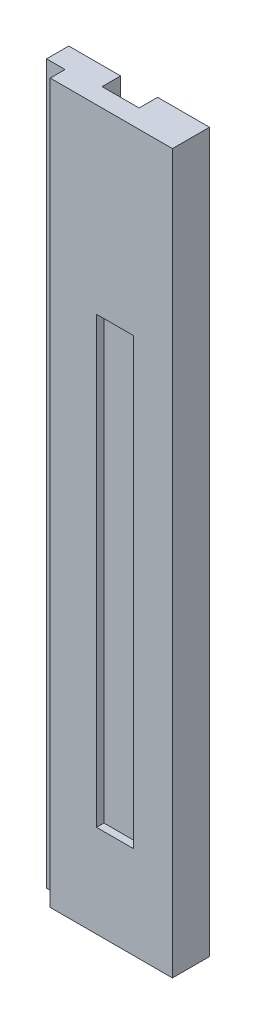
from build123d import *

# Parameters (mm, degrees)
SKETCH1_W            = 14
SKETCH1_H            = 100
BOSS_EXTRUDE1_DEPTH  = 2
SKETCH2_W            = 2
SKETCH2_H            = 100
BOSS_EXTRUDE2_DEPTH  = 4
SKETCH3_W            = 2
SKETCH3_H            = 100
BOSS_EXTRUDE4_DEPTH  = 2
SKETCH4_W            = 2
SKETCH4_H            = 100
BOSS_EXTRUDE5_DEPTH  = 2
SKETCH6_W            = 18
SKETCH6_H            = 100
BOSS_EXTRUDE6_DEPTH  = 1
SKETCH7_W            = 3
SKETCH7_H            = 100
CUT_EXTRUDE1_DEPTH   = 1
BOSS_EXTRUDE7_DEPTH  = 50
SKETCH9_W            = 3
SKETCH9_H            = 1
CUT_EXTRUDE2_DEPTH   = 150
SKETCH10_W           = 3
SKETCH10_H           = 1
BOSS_EXTRUDE8_DEPTH  = 150
SKETCH11_W           = 2
SKETCH11_H           = 50
CUT_EXTRUDE3_DEPTH   = 50
SKETCH14_W           = 16
SKETCH14_H           = 30
CUT_EXTRUDE4_DEPTH   = 50
SKETCH15_W           = 10
SKETCH15_H           = 2
BOSS_EXTRUDE9_DEPTH  = 4
SKETCH16_W           = 10
SKETCH16_H           = 8
BOSS_EXTRUDE10_DEPTH = 4
SKETCH21_W           = 10
SKETCH21_H           = 8
CUT_EXTRUDE5_DEPTH   = 4
SKETCH23_W           = 16
SKETCH23_H           = 120
CUT_EXTRUDE7_DEPTH   = 2
SKETCH24_W           = 3
SKETCH24_H           = 40
BOSS_EXTRUDE13_DEPTH = 1
BOSS_EXTRUDE14_DEPTH = 50
SKETCH27_W           = 2
SKETCH27_H           = 170
BOSS_EXTRUDE15_DEPTH = 2
SKETCH28_W           = 5
SKETCH28_H           = 170
BOSS_EXTRUDE16_DEPTH = 18
SKETCH29_W           = 5
SKETCH29_H           = 170
BOSS_EXTRUDE17_DEPTH = 40
SKETCH30_W           = 1
SKETCH30_H           = 170
BOSS_EXTRUDE18_DEPTH = 1
SKETCH31_W           = 1
SKETCH31_H           = 170
BOSS_EXTRUDE19_DEPTH = 1
SKETCH32_W           = 10
SKETCH32_H           = 170
CUT_EXTRUDE8_DEPTH   = 2
SKETCH33_W           = 40
SKETCH33_H           = 4
BOSS_EXTRUDE20_DEPTH = 1
SKETCH34_W           = 10
SKETCH34_H           = 40
BOSS_EXTRUDE21_DEPTH = 2
SKETCH35_W           = 3
SKETCH35_H           = 170
CUT_EXTRUDE9_DEPTH   = 1
SKETCH36_W           = 1
SKETCH36_H           = 170
BOSS_EXTRUDE22_DEPTH = 1
SKETCH37_W           = 1
SKETCH37_H           = 170
CUT_EXTRUDE10_DEPTH  = 2
SKETCH39_W           = 6
SKETCH39_H           = 170
CUT_EXTRUDE11_DEPTH  = 4
SKETCH40_W           = 10
SKETCH40_H           = 129
BOSS_EXTRUDE23_DEPTH = 2
SKETCH41_W           = 10
SKETCH41_H           = 120
CUT_EXTRUDE12_DEPTH  = 2
BOSS_EXTRUDE24_DEPTH = 30
CUT_EXTRUDE13_DEPTH  = 30
SKETCH45_W           = 10
SKETCH45_H           = 120
CUT_EXTRUDE14_DEPTH  = 2
SKETCH46_W           = 10
SKETCH46_H           = 20
BOSS_EXTRUDE25_DEPTH = 2
SKETCH47_W           = 10
SKETCH47_H           = 5
BOSS_EXTRUDE26_DEPTH = 2
SKETCH48_W           = 10
SKETCH48_H           = 5
CUT_EXTRUDE15_DEPTH  = 2
SKETCH52_W           = 10
SKETCH52_H           = 120
BOSS_EXTRUDE27_DEPTH = 2
SKETCH53_W           = 10
SKETCH53_H           = 120
CUT_EXTRUDE16_DEPTH  = 2
SKETCH54_W           = 15
SKETCH54_H           = 170
BOSS_EXTRUDE28_DEPTH = 5
SKETCH55_W           = 1
SKETCH55_H           = 170
CUT_EXTRUDE17_DEPTH  = 1
SKETCH56_W           = 1
SKETCH56_H           = 170
CUT_EXTRUDE18_DEPTH  = 10
SKETCH57_W           = 1
SKETCH57_H           = 170
CUT_EXTRUDE19_DEPTH  = 11
BOSS_EXTRUDE29_DEPTH = 14
CUT_EXTRUDE20_DEPTH  = 14
BOSS_EXTRUDE30_DEPTH = 14
BOSS_EXTRUDE31_DEPTH = 10


with BuildPart() as part:
    # Sketch1 → Boss-Extrude1 (new body)
    with BuildSketch(Plane.XY):
        with Locations((-7, 38.971731826)):
            Rectangle(SKETCH1_W, SKETCH1_H)
    extrude(amount=BOSS_EXTRUDE1_DEPTH)

    # Sketch2 → Boss-Extrude2 (add)
    with BuildSketch(Plane.XY.offset(2)):
        with Locations((-13, 38.971731826)):
            Rectangle(SKETCH2_W, SKETCH2_H)
        with Locations((-1, 38.971731826)):
            Rectangle(SKETCH2_W, SKETCH2_H)
    extrude(amount=BOSS_EXTRUDE2_DEPTH)

    # Sketch3 → Boss-Extrude4 (add)
    with BuildSketch(Plane(origin=(0, 0, 0), x_dir=(0, 0, -1), z_dir=(1, 0, 0))):
        with Locations((-1, 38.971731826)):
            Rectangle(SKETCH3_W, SKETCH3_H)
    extrude(amount=BOSS_EXTRUDE4_DEPTH)

    # Sketch4 → Boss-Extrude5 (add)
    with BuildSketch(Plane.ZY.offset(14)):
        with Locations((1, 38.971731826)):
            Rectangle(SKETCH4_W, SKETCH4_H)
    extrude(amount=BOSS_EXTRUDE5_DEPTH)

    # Sketch6 → Boss-Extrude6 (add)
    with BuildSketch(Plane(origin=(0, 0, 0), x_dir=(-1, 0, 0), z_dir=(0, 0, -1))):
        with Locations((7, 38.971731826)):
            Rectangle(SKETCH6_W, SKETCH6_H)
    extrude(amount=BOSS_EXTRUDE6_DEPTH)

    # Sketch7 → Cut-Extrude1 (cut)
    with BuildSketch(Plane(origin=(0, 0, -1), x_dir=(-1, 0, 0), z_dir=(0, 0, -1))):
        with Locations((7, 38.971731826)):
            Rectangle(SKETCH7_W, SKETCH7_H)
    extrude(amount=-CUT_EXTRUDE1_DEPTH, mode=Mode.SUBTRACT)

    # Sketch8 → Boss-Extrude7 (add)
    with BuildSketch(Plane(origin=(0, 88.971731826, 0), x_dir=(1, 0, 0), z_dir=(0, 1, 0))):
        Polygon((2, 1), (-5.5, 1), (-5.5, 0), (-8.5, 0), (-8.5, 1), (-16, 1), (-16, -2), (-14, -2), (-14, -6), (-12, -6), (-12, -2), (-2, -2), (-2, -6), (0, -6), (0, -2), (2, -2), align=None)
    extrude(amount=BOSS_EXTRUDE7_DEPTH)

    # Sketch9 → Cut-Extrude2 (cut)
    with BuildSketch(Plane(origin=(0, 138.971731826, 0), x_dir=(1, 0, 0), z_dir=(0, 1, 0))):
        with Locations((-10, 0.5)):
            Rectangle(SKETCH9_W, SKETCH9_H)
    extrude(amount=-CUT_EXTRUDE2_DEPTH, mode=Mode.SUBTRACT)

    # Sketch10 → Boss-Extrude8 (add)
    with BuildSketch(Plane(origin=(0, 138.971731826, 0), x_dir=(1, 0, 0), z_dir=(0, 1, 0))):
        with Locations((-7, 0.5)):
            Rectangle(SKETCH10_W, SKETCH10_H)
    extrude(amount=-BOSS_EXTRUDE8_DEPTH)

    # Sketch11 → Cut-Extrude3 (cut)
    with BuildSketch(Plane.XY.offset(2)):
        with Locations((-15, 13.971731826)):
            Rectangle(SKETCH11_W, SKETCH11_H)
    extrude(amount=-CUT_EXTRUDE3_DEPTH, mode=Mode.SUBTRACT)

    # Sketch14 → Cut-Extrude4 (cut)
    with BuildSketch(Plane.XY.offset(6)):
        with Locations((-6, 3.971731826)):
            Rectangle(SKETCH14_W, SKETCH14_H)
    extrude(amount=-CUT_EXTRUDE4_DEPTH, mode=Mode.SUBTRACT)

    # Sketch15 → Boss-Extrude9 (add)
    with BuildSketch(Plane.XY.offset(2)):
        with Locations((-7, 137.971731826)):
            Rectangle(SKETCH15_W, SKETCH15_H)
    extrude(amount=BOSS_EXTRUDE9_DEPTH)

    # Sketch16 → Boss-Extrude10 (add)
    with BuildSketch(Plane.XY.offset(2)):
        with Locations((-7, 132.971731826)):
            Rectangle(SKETCH16_W, SKETCH16_H)
    extrude(amount=BOSS_EXTRUDE10_DEPTH)

    # Sketch21 → Cut-Extrude5 (cut)
    with BuildSketch(Plane.XY.offset(6)):
        with Locations((-7, 132.971731826)):
            Rectangle(SKETCH21_W, SKETCH21_H)
    extrude(amount=-CUT_EXTRUDE5_DEPTH, mode=Mode.SUBTRACT)

    # Sketch23 → Cut-Extrude7 (cut)
    with BuildSketch(Plane.XY.offset(6)):
        with Locations((-6, 78.971731826)):
            Rectangle(SKETCH23_W, SKETCH23_H)
    extrude(amount=-CUT_EXTRUDE7_DEPTH, mode=Mode.SUBTRACT)

    # Sketch24 → Boss-Extrude13 (add)
    with BuildSketch(Plane(origin=(0, 0, 0), x_dir=(-1, 0, 0), z_dir=(0, 0, -1))):
        with Locations((10, 118.971731826)):
            Rectangle(SKETCH24_W, SKETCH24_H)
    extrude(amount=BOSS_EXTRUDE13_DEPTH)

    # Sketch26 → Boss-Extrude14 (add)
    with BuildSketch(Plane.XZ.offset(-18.971731826)):
        Polygon((-14, 4), (-12, 4), (-12, 2), (-2, 2), (-2, 4), (0, 4), (0, 2), (2, 2), (2, -1), (-8.5, -1), (-8.5, 0), (-11.5, 0), (-11.5, -1), (-14, -1), align=None)
    extrude(amount=BOSS_EXTRUDE14_DEPTH)

    # Sketch27 → Boss-Extrude15 (add, through all)
    with BuildSketch(Plane(origin=(0, 0, 0), x_dir=(0, 0, -1), z_dir=(1, 0, 0))):
        with Locations((-3, 53.971731826)):
            Rectangle(SKETCH27_W, SKETCH27_H)
    extrude(amount=BOSS_EXTRUDE15_DEPTH)

    # Sketch28 → Boss-Extrude16 (add)
    with BuildSketch(Plane(origin=(2, 0, 0), x_dir=(0, 0, -1), z_dir=(1, 0, 0))):
        with Locations((-1.5, 53.971731826)):
            Rectangle(SKETCH28_W, SKETCH28_H)
    extrude(amount=BOSS_EXTRUDE16_DEPTH)

    # Sketch29 → Boss-Extrude17 (add)
    with BuildSketch(Plane(origin=(20, 0, 0), x_dir=(0, 0, -1), z_dir=(1, 0, 0))):
        with Locations((-1.5, 53.971731826)):
            Rectangle(SKETCH29_W, SKETCH29_H)
    extrude(amount=-BOSS_EXTRUDE17_DEPTH)

    # Sketch30 → Boss-Extrude18 (add)
    with BuildSketch(Plane.ZY.offset(20)):
        with Locations((3.5, 53.971731826)):
            Rectangle(SKETCH30_W, SKETCH30_H)
    extrude(amount=BOSS_EXTRUDE18_DEPTH)

    # Sketch31 → Boss-Extrude19 (add)
    with BuildSketch(Plane(origin=(20, 0, 0), x_dir=(0, 0, -1), z_dir=(1, 0, 0))):
        with Locations((-3.5, 53.971731826)):
            Rectangle(SKETCH31_W, SKETCH31_H)
    extrude(amount=BOSS_EXTRUDE19_DEPTH)

    # Sketch32 → Cut-Extrude8 (cut)
    with BuildSketch(Plane(origin=(0, 0, -1), x_dir=(-1, 0, 0), z_dir=(0, 0, -1))):
        with Locations((0, 53.971731826)):
            Rectangle(SKETCH32_W, SKETCH32_H)
    extrude(amount=-CUT_EXTRUDE8_DEPTH, mode=Mode.SUBTRACT)

    # Sketch33 → Boss-Extrude20 (add)
    with BuildSketch(Plane(origin=(0, 138.971731826, 0), x_dir=(1, 0, 0), z_dir=(0, 1, 0))):
        with Locations((0, -1)):
            Rectangle(SKETCH33_W, SKETCH33_H)
    extrude(amount=-BOSS_EXTRUDE20_DEPTH)

    # Sketch34 → Boss-Extrude21 (add, through all)
    with BuildSketch(Plane(origin=(0, 0, 1), x_dir=(-1, 0, 0), z_dir=(0, 0, -1))):
        with Locations((0, -11.028268174)):
            Rectangle(SKETCH34_W, SKETCH34_H)
    extrude(amount=BOSS_EXTRUDE21_DEPTH)

    # Sketch35 → Cut-Extrude9 (cut)
    with BuildSketch(Plane.XY.offset(4)):
        with Locations((-18, 53.971731826)):
            Rectangle(SKETCH35_W, SKETCH35_H)
    extrude(amount=-CUT_EXTRUDE9_DEPTH, mode=Mode.SUBTRACT)

    # Sketch36 → Boss-Extrude22 (add)
    with BuildSketch(Plane.ZY.offset(20)):
        with Locations((-0.5, 53.971731826)):
            Rectangle(SKETCH36_W, SKETCH36_H)
    extrude(amount=BOSS_EXTRUDE22_DEPTH)

    # Sketch37 → Cut-Extrude10 (cut, through all)
    with BuildSketch(Plane(origin=(0, 0, 3), x_dir=(-1, 0, 0), z_dir=(0, 0, -1))):
        with Locations((20.5, 53.971731826)):
            Rectangle(SKETCH37_W, SKETCH37_H)
    extrude(amount=-CUT_EXTRUDE10_DEPTH, mode=Mode.SUBTRACT)

    # Sketch39 → Cut-Extrude11 (cut)
    with BuildSketch(Plane.XY.offset(4)):
        with Locations((-17, 53.971731826)):
            Rectangle(SKETCH39_W, SKETCH39_H)
    extrude(amount=-CUT_EXTRUDE11_DEPTH, mode=Mode.SUBTRACT)

    # Sketch40 → Boss-Extrude23 (add, through all)
    with BuildSketch(Plane(origin=(0, 0, 1), x_dir=(-1, 0, 0), z_dir=(0, 0, -1))):
        with Locations((0, 73.471731826)):
            Rectangle(SKETCH40_W, SKETCH40_H)
    extrude(amount=BOSS_EXTRUDE23_DEPTH)

    # Sketch41 → Cut-Extrude12 (cut)
    with BuildSketch(Plane.XY.offset(4)):
        with Locations((0, 38.971731826)):
            Rectangle(SKETCH41_W, SKETCH41_H)
    extrude(amount=-CUT_EXTRUDE12_DEPTH, mode=Mode.SUBTRACT)

    # Sketch43 → Boss-Extrude24 (add)
    with BuildSketch(Plane.XZ.offset(31.028268174)):
        Polygon((-21, -1), (-21, 0), (-14, 0), (-14, 4), (21, 4), (21, 3), (20, 3), (20, -1), align=None)
    extrude(amount=BOSS_EXTRUDE24_DEPTH)

    # Sketch44 → Cut-Extrude13 (cut)
    with BuildSketch(Plane(origin=(0, 138.971731826, 0), x_dir=(1, 0, 0), z_dir=(0, 1, 0))):
        Polygon((-21, 1), (20, 1), (20, -3), (21, -3), (21, -4), (-14, -4), (-14, 0), (-21, 0), align=None)
    extrude(amount=-CUT_EXTRUDE13_DEPTH, mode=Mode.SUBTRACT)

    # Sketch45 → Cut-Extrude14 (cut)
    with BuildSketch(Plane.XY.offset(4)):
        with Locations((0, 18.971731826)):
            Rectangle(SKETCH45_W, SKETCH45_H)
    extrude(amount=-CUT_EXTRUDE14_DEPTH, mode=Mode.SUBTRACT)

    # Sketch46 → Boss-Extrude25 (add)
    with BuildSketch(Plane.XY.offset(4)):
        with Locations((0, 88.971731826)):
            Rectangle(SKETCH46_W, SKETCH46_H)
    extrude(amount=-BOSS_EXTRUDE25_DEPTH)

    # Sketch47 → Boss-Extrude26 (add)
    with BuildSketch(Plane.XY.offset(4)):
        with Locations((0, -38.528268174)):
            Rectangle(SKETCH47_W, SKETCH47_H)
    extrude(amount=-BOSS_EXTRUDE26_DEPTH)

    # Sketch48 → Cut-Extrude15 (cut)
    with BuildSketch(Plane.XY.offset(4)):
        with Locations((0, 81.471731826)):
            Rectangle(SKETCH48_W, SKETCH48_H)
    extrude(amount=-CUT_EXTRUDE15_DEPTH, mode=Mode.SUBTRACT)

    # Sketch52 → Boss-Extrude27 (add)
    with BuildSketch(Plane.XY.offset(4)):
        with Locations((0, 23.971731826)):
            Rectangle(SKETCH52_W, SKETCH52_H)
    extrude(amount=-BOSS_EXTRUDE27_DEPTH)

    # Sketch53 → Cut-Extrude16 (cut)
    with BuildSketch(Plane.XY.offset(4)):
        with Locations((3.5, 23.971731826)):
            Rectangle(SKETCH53_W, SKETCH53_H)
    extrude(amount=-CUT_EXTRUDE16_DEPTH, mode=Mode.SUBTRACT)

    # Sketch54 → Boss-Extrude28 (add)
    with BuildSketch(Plane(origin=(0, 0, -1), x_dir=(-1, 0, 0), z_dir=(0, 0, -1))):
        with Locations((-12.5, 23.971731826)):
            Rectangle(SKETCH54_W, SKETCH54_H)
        with Locations((12.5, 23.971731826)):
            Rectangle(SKETCH54_W, SKETCH54_H)
    extrude(amount=BOSS_EXTRUDE28_DEPTH)

    # Sketch55 → Cut-Extrude17 (cut)
    with BuildSketch(Plane(origin=(0, 0, -1), x_dir=(-1, 0, 0), z_dir=(0, 0, -1))):
        with Locations((20.5, 23.971731826)):
            Rectangle(SKETCH55_W, SKETCH55_H)
    extrude(amount=-CUT_EXTRUDE17_DEPTH, mode=Mode.SUBTRACT)

    # Sketch56 → Cut-Extrude18 (cut)
    with BuildSketch(Plane(origin=(0, 0, 3), x_dir=(-1, 0, 0), z_dir=(0, 0, -1))):
        with Locations((-20.5, 23.971731826)):
            Rectangle(SKETCH56_W, SKETCH56_H)
    extrude(amount=-CUT_EXTRUDE18_DEPTH, mode=Mode.SUBTRACT)

    # Sketch57 → Cut-Extrude19 (cut, through all)
    with BuildSketch(Plane.XY.offset(4)):
        with Locations((19.5, 23.971731826)):
            Rectangle(SKETCH57_W, SKETCH57_H)
        with Locations((-19.5, 23.971731826)):
            Rectangle(SKETCH57_W, SKETCH57_H)
    extrude(amount=-CUT_EXTRUDE19_DEPTH, mode=Mode.SUBTRACT)

    # Sketch58 → Boss-Extrude29 (add)
    with BuildSketch(Plane.XZ.offset(61.028268174)):
        Polygon((-19, -6), (-5, -6), (-5, -1), (5, -1), (5, -6), (19, -6), (19, 4), (-14, 4), (-14, 0), (-19, 0), align=None)
    extrude(amount=BOSS_EXTRUDE29_DEPTH)

    # Sketch59 → Cut-Extrude20 (cut)
    with BuildSketch(Plane.XZ.offset(75.028268174)):
        Polygon((-19, -6), (-19, 0), (-14, 0), (-14, 4), (19, 4), (19, -6), (5, -6), (5, -1), (-5, -1), (-5, -6), align=None)
    extrude(amount=-CUT_EXTRUDE20_DEPTH, mode=Mode.SUBTRACT)

    # Sketch60 → Boss-Extrude30 (add)
    with BuildSketch(Plane(origin=(0, 108.971731826, 0), x_dir=(1, 0, 0), z_dir=(0, 1, 0))):
        Polygon((-19, 6), (-5, 6), (-5, 1), (5, 1), (5, 6), (19, 6), (19, -4), (-14, -4), (-14, 0), (-19, 0), align=None)
    extrude(amount=BOSS_EXTRUDE30_DEPTH)

    # Sketch61 → Boss-Extrude31 (add)
    with BuildSketch(Plane(origin=(0, 122.971731826, 0), x_dir=(1, 0, 0), z_dir=(0, 1, 0))):
        Polygon((-19, 6), (-5, 6), (-5, 1), (5, 1), (5, 6), (19, 6), (19, -4), (-14, -4), (-14, 0), (-19, 0), align=None)
    extrude(amount=BOSS_EXTRUDE31_DEPTH)


solid = part.part
